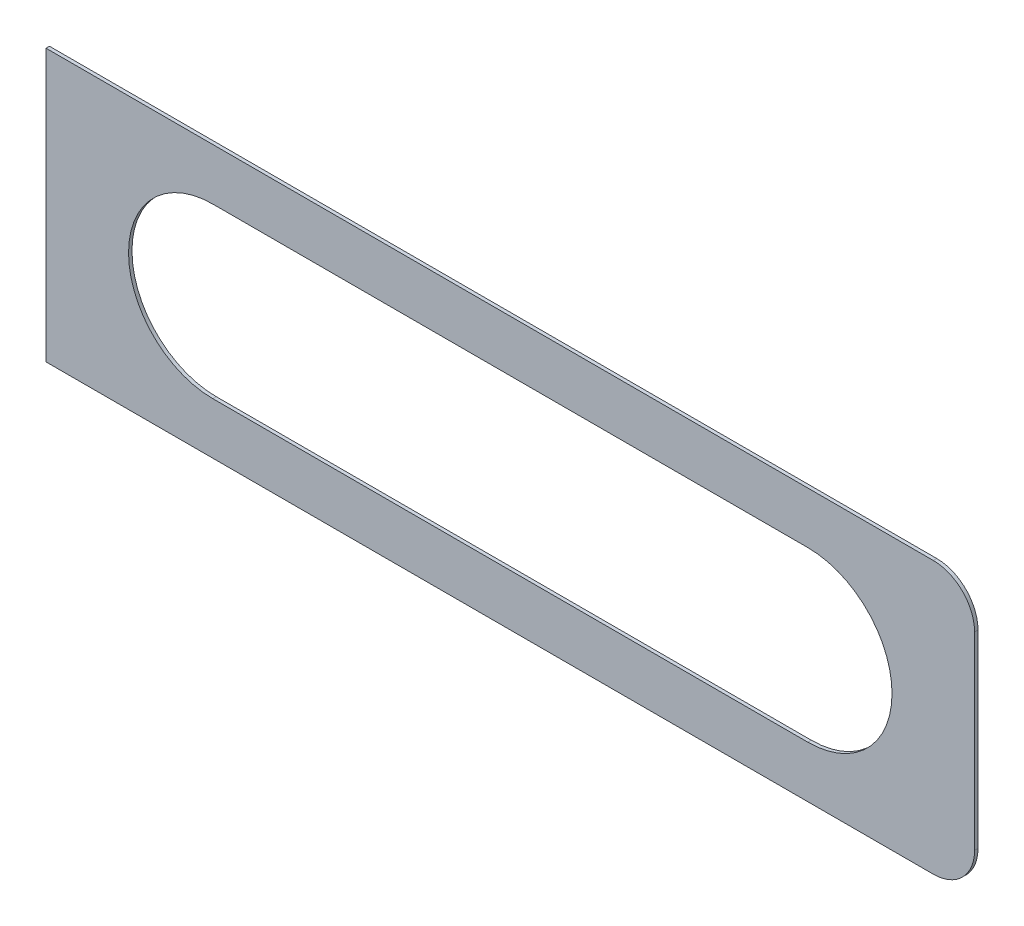
from build123d import *

# Parameters (mm, degrees)
BOSS_EXTRUDE1_DEPTH = 0.254
CUT_EXTRUDE1_DEPTH  = 0.254


with BuildPart() as part:
    # Sketch1 → Boss-Extrude1 (new body)
    with BuildSketch(Plane.XY):
        with BuildLine():
            Line((-34.29, 10.033), (31.242, 10.033))
            ThreePointArc((31.242, 10.033), (33.397261469, 9.140261469), (34.29, 6.985))
            Line((34.29, 6.985), (34.29, -6.985))
            ThreePointArc((34.29, -6.985), (33.397261469, -9.140261469), (31.242, -10.033))
            Line((31.242, -10.033), (-34.29, -10.033))
            Line((-34.29, -10.033), (-34.29, 10.033))
        make_face()
    extrude(amount=BOSS_EXTRUDE1_DEPTH)

    # Sketch2 → Cut-Extrude1 (cut)
    with BuildSketch(Plane.XY.offset(0.254)):
        with BuildLine():
            Line((-21.971, 6.223), (21.971, 6.223))
            ThreePointArc((21.971, 6.223), (28.194, 0), (21.971, -6.223))
            Line((21.971, -6.223), (-21.971, -6.223))
            ThreePointArc((-21.971, -6.223), (-28.194, 0), (-21.971, 6.223))
        make_face()
    extrude(amount=-CUT_EXTRUDE1_DEPTH, mode=Mode.SUBTRACT)


solid = part.part
